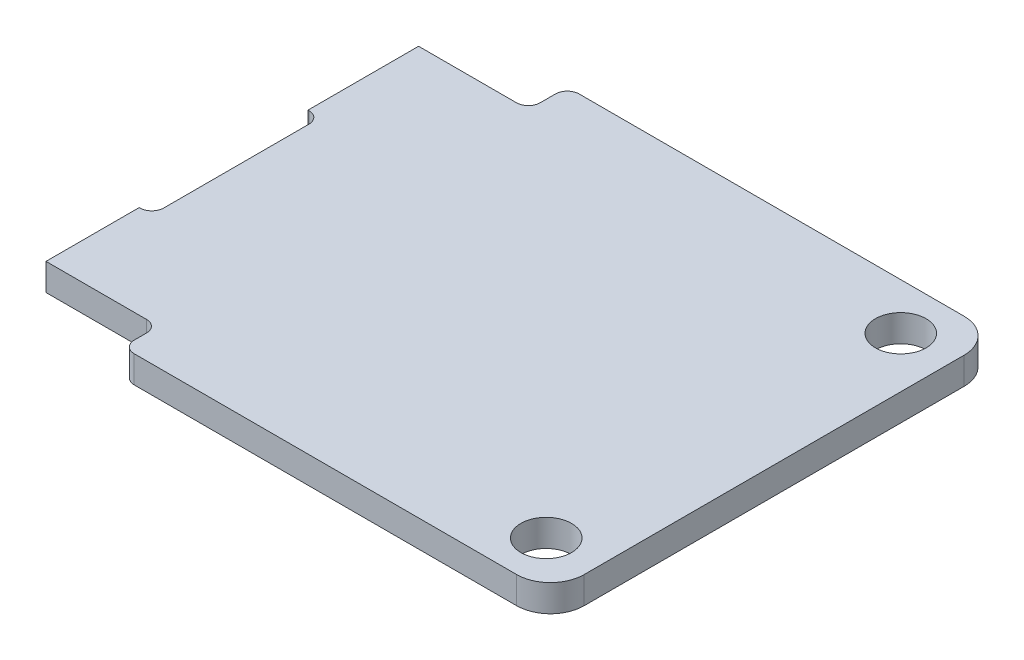
from build123d import *

# Parameters (mm, degrees)
SKETCH1_R           = 1.5
BOSS_EXTRUDE1_DEPTH = 1.6


with BuildPart() as part:
    # Sketch1 → Boss-Extrude1 (new body)
    with BuildSketch(Plane(origin=(0, 0, 0), x_dir=(1, 0, 0), z_dir=(0, 1, 0))):
        with BuildLine():
            Line((-9.702113495, 11.642067097), (-9.702113495, 12.55))
            ThreePointArc((-9.702113495, 12.55), (-9.497088242, 13.044974747), (-9.002113495, 13.25))
            Line((-9.002113495, 13.25), (13.797886505, 13.25))
            ThreePointArc((13.797886505, 13.25), (15.212100067, 12.664213562), (15.797886505, 11.25))
            Line((15.797886505, 11.25), (15.797886505, -11.25))
            ThreePointArc((15.797886505, -11.25), (15.212100067, -12.664213562), (13.797886505, -13.25))
            Line((13.797886505, -13.25), (-8.850291446, -13.25))
            ThreePointArc((-8.850291446, -13.25), (-9.345266193, -13.044974747), (-9.550291446, -12.55))
            Line((-9.550291446, -12.55), (-9.550291446, -11.824237104))
            ThreePointArc((-9.550291446, -11.824237104), (-9.7553167, -11.329262357), (-10.250291446, -11.124237104))
            Line((-10.250291446, -11.124237104), (-16.202113495, -11.124237104))
            Line((-16.202113495, -11.124237104), (-16.202113495, -5.604412091))
            Line((-16.202113495, -5.604412091), (-16.152113495, -5.604412091))
            ThreePointArc((-16.152113495, -5.604412091), (-15.657138749, -5.399386838), (-15.452113495, -4.904412091))
            Line((-15.452113495, -4.904412091), (-15.452113495, 3.695587909))
            ThreePointArc((-15.452113495, 3.695587909), (-15.657138749, 4.190562656), (-16.152113495, 4.395587909))
            Line((-16.152113495, 4.395587909), (-16.202113495, 4.395587909))
            Line((-16.202113495, 4.395587909), (-16.202113495, 10.942067097))
            Line((-16.202113495, 10.942067097), (-10.402113495, 10.942067097))
            ThreePointArc((-10.402113495, 10.942067097), (-9.907138749, 11.14709235), (-9.702113495, 11.642067097))
        make_face()
        with Locations((12.797886505, 10.5)):
            Circle(SKETCH1_R, mode=Mode.SUBTRACT)
        with Locations((12.797886505, -10.5)):
            Circle(SKETCH1_R, mode=Mode.SUBTRACT)
    extrude(amount=BOSS_EXTRUDE1_DEPTH)


solid = part.part
